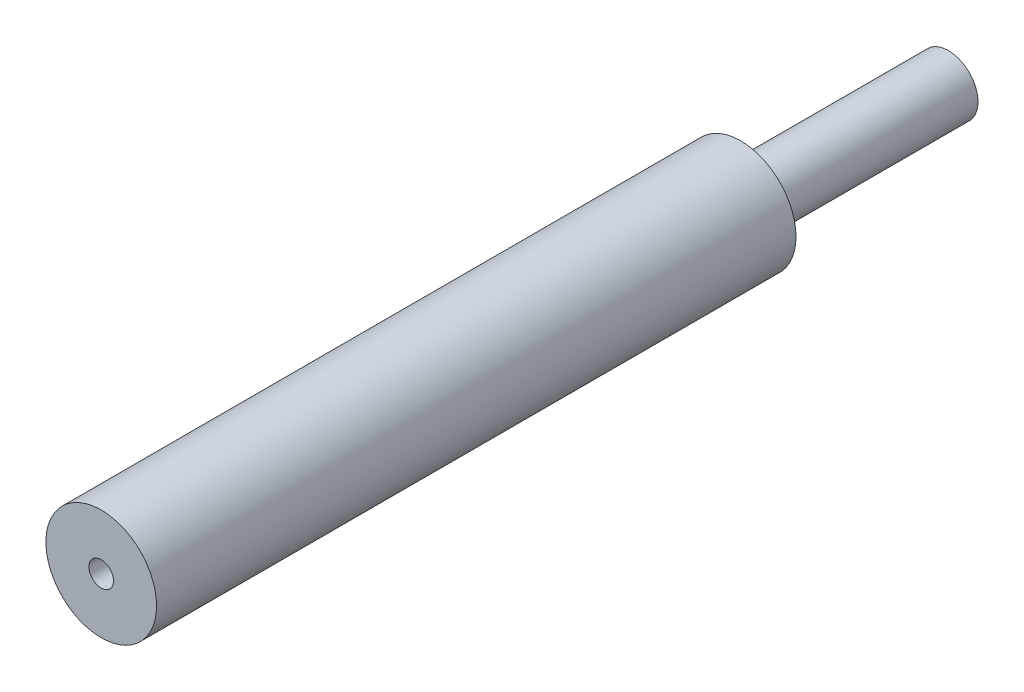
from build123d import *

# Parameters (mm, degrees)
SKETCH1_R           = 1.2
SKETCH1_R_2         = 0.5
BOSS_EXTRUDE1_DEPTH = 8.45
SKETCH2_R           = 2.25
SKETCH2_R_2         = 0.5
BOSS_EXTRUDE2_DEPTH = 26


with BuildPart() as part:
    # Sketch1 → Boss-Extrude1 (new body)
    with BuildSketch(Plane.XY):
        Circle(SKETCH1_R)
        Circle(SKETCH1_R_2, mode=Mode.SUBTRACT)
    extrude(amount=BOSS_EXTRUDE1_DEPTH)

    # Sketch2 → Boss-Extrude2 (add)
    with BuildSketch(Plane.XY.offset(8.45)):
        Circle(SKETCH2_R)
        Circle(SKETCH2_R_2, mode=Mode.SUBTRACT)
    extrude(amount=BOSS_EXTRUDE2_DEPTH)


solid = part.part
